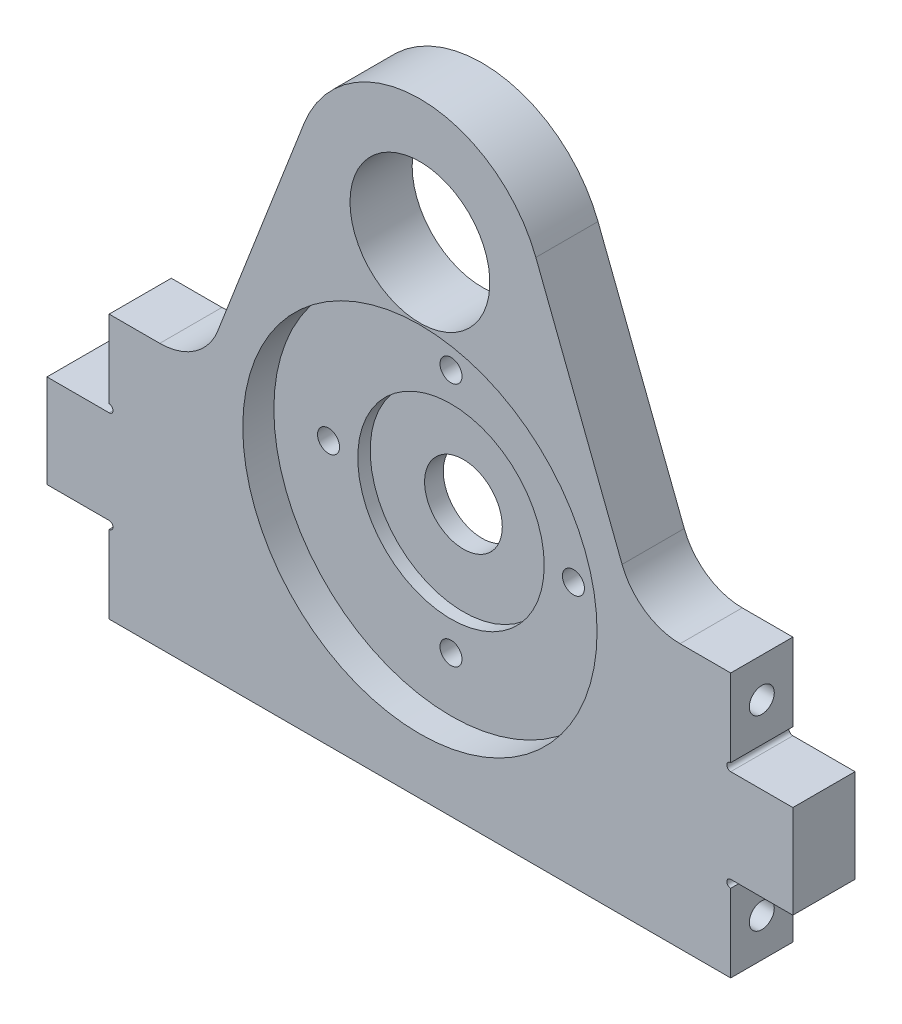
from build123d import *

# Parameters (mm, degrees)
SKETCH1_W                                      = 127
SKETCH1_H                                      = 152.4
BOSS_EXTRUDE1_DEPTH                            = 12.7
SKETCH2_R                                      = 14.2875
CUT_EXTRUDE1_DEPTH                             = 166.587741092
SKETCH3_R                                      = 7.9375
SKETCH3_R_2                                    = 1.016
CUT_EXTRUDE2_DEPTH                             = 137.930502446
SKETCH4_R                                      = 36.195
CUT_EXTRUDE3_DEPTH                             = 6.35
SKETCH5_R                                      = 19.05
CUT_EXTRUDE4_DEPTH                             = 2.54
CSK_FOR_8_FLAT_HEAD_MACHINE_SCREW1_D           = 4.4958
CSK_FOR_8_FLAT_HEAD_MACHINE_SCREW1_CSINK_D     = 8.4328
CSK_FOR_8_FLAT_HEAD_MACHINE_SCREW1_CSINK_ANGLE = 82
FILLET1_R                                      = 12.7
SKETCH8_W                                      = 127
SKETCH8_H                                      = 3.175
BOSS_EXTRUDE2_DEPTH                            = 12.7
F_1_4_20_TAPPED_HOLE1_AT_2_COUNT               = 2
F_1_4_20_TAPPED_HOLE1_AT_2_PITCH               = 38.1
SKETCH11_W                                     = 12.7
SKETCH11_H                                     = 19.05
BOSS_EXTRUDE3_DEPTH                            = 12.7
SKETCH12_R                                     = 0.79375
CUT_EXTRUDE5_DEPTH                             = 144.262529993


with BuildPart() as part:
    # Sketch1 → Boss-Extrude1 (new body)
    with BuildSketch(Plane.XY):
        with Locations((0, 76.2)):
            Rectangle(SKETCH1_W, SKETCH1_H)
    extrude(amount=BOSS_EXTRUDE1_DEPTH)

    # Sketch2 → Cut-Extrude1 (cut, through all)
    with BuildSketch(Plane(origin=(0, 0, 0), x_dir=(-1, 0, 0), z_dir=(0, 0, -1))):
        with BuildLine():
            Line((44.45, 50.8), (63.5, 50.8))
            Line((63.5, 50.8), (63.5, 152.4))
            Line((63.5, 152.4), (-63.5, 152.4))
            Line((-63.5, 152.4), (-63.5, 50.8))
            Line((-63.5, 50.8), (-44.45, 50.8))
            Line((-44.45, 50.8), (-23.686198751, 104.421913036))
            ThreePointArc((-23.686198751, 104.421913036), (0, 120.65), (23.686198751, 104.421913036))
            Line((23.686198751, 104.421913036), (44.45, 50.8))
        make_face()
        with Locations((0, 95.25)):
            Circle(SKETCH2_R)
    extrude(amount=-CUT_EXTRUDE1_DEPTH, mode=Mode.SUBTRACT)

    # Sketch3 → Cut-Extrude2 (cut, through all)
    with BuildSketch(Plane.XY.offset(12.7)):
        with Locations((0, 44.45)):
            Circle(SKETCH3_R)
        with Locations((-25.019, 44.45)):
            Circle(SKETCH3_R_2)
        with Locations((25.019, 44.45)):
            Circle(SKETCH3_R_2)
        with Locations((0, 69.469)):
            Circle(SKETCH3_R_2)
        with Locations((0, 19.431)):
            Circle(SKETCH3_R_2)
    extrude(amount=-CUT_EXTRUDE2_DEPTH, mode=Mode.SUBTRACT)

    # Sketch4 → Cut-Extrude3 (cut)
    with BuildSketch(Plane.XY.offset(12.7)):
        with Locations((0, 44.45)):
            Circle(SKETCH4_R)
    extrude(amount=-CUT_EXTRUDE3_DEPTH, mode=Mode.SUBTRACT)

    # Sketch5 → Cut-Extrude4 (cut)
    with BuildSketch(Plane.XY.offset(6.35)):
        with Locations((0, 44.45)):
            Circle(SKETCH5_R)
    extrude(amount=-CUT_EXTRUDE4_DEPTH, mode=Mode.SUBTRACT)

    # CSK for _8 Flat Head Machine Screw1 (through all)
    with Locations(Plane(origin=(0, 0, 0), x_dir=(-1, 0, 0), z_dir=(0, 0, -1))):
        with Locations((0, 69.469), (25.019, 44.45), (0, 19.431), (-25.019, 44.45)):
            CounterSinkHole(CSK_FOR_8_FLAT_HEAD_MACHINE_SCREW1_D / 2, CSK_FOR_8_FLAT_HEAD_MACHINE_SCREW1_CSINK_D / 2, counter_sink_angle=CSK_FOR_8_FLAT_HEAD_MACHINE_SCREW1_CSINK_ANGLE)

    # Fillet1
    fillet1_edges = [part.edges().sort_by_distance(p)[0] for p in [
        (-44.45, 50.8, 6.35),
        (44.45, 50.8, 6.35),
    ]]
    fillet(fillet1_edges, radius=FILLET1_R)

    # Sketch8 → Boss-Extrude2 (add)
    with BuildSketch(Plane(origin=(0, 0, 0), x_dir=(-1, 0, 0), z_dir=(0, 0, -1))):
        with Locations((0, -1.5875)):
            Rectangle(SKETCH8_W, SKETCH8_H)
    extrude(amount=-BOSS_EXTRUDE2_DEPTH)

    # Sketch9 → 1_4-20 Tapped Hole1 (revolve, cut)
    with BuildSketch(Plane(origin=(63.5, 42.8625, 6.35), x_dir=(0, 0, -1), z_dir=(0, 1, 0))):
        Polygon((0, 0), (0, 18.043816902), (2.5527, 16.51), (2.5527, 0), align=None)
    f_1_4_20_tapped_hole1 = revolve(axis=Axis((69.85, 42.8625, 6.35), (-1, 0, 0)), mode=Mode.SUBTRACT)

    # 1_4-20 Tapped Hole1 at 2: 1_4-20 Tapped Hole1 ×2
    with Locations(*[(0, -i * F_1_4_20_TAPPED_HOLE1_AT_2_PITCH, 0) for i in range(1, F_1_4_20_TAPPED_HOLE1_AT_2_COUNT)]):
        add(f_1_4_20_tapped_hole1, mode=Mode.SUBTRACT)

    # Sketch11 → Boss-Extrude3 (add)
    with BuildSketch(Plane(origin=(63.5, 0, 0), x_dir=(0, 0, -1), z_dir=(1, 0, 0))):
        with Locations((-6.35, 23.8125)):
            Rectangle(SKETCH11_W, SKETCH11_H)
    boss_extrude3 = extrude(amount=BOSS_EXTRUDE3_DEPTH)

    # Sketch12 → Cut-Extrude5 (cut, through all)
    with BuildSketch(Plane.XY.offset(12.7)):
        with Locations((63.5, 34.13125)):
            Circle(SKETCH12_R)
        with Locations((63.5, 13.49375)):
            Circle(SKETCH12_R)
    cut_extrude5 = extrude(amount=-CUT_EXTRUDE5_DEPTH, mode=Mode.SUBTRACT)

    # Mirror1: 1_4-20 Tapped Hole1, Boss-Extrude3, Cut-Extrude5 across plane
    add(f_1_4_20_tapped_hole1.mirror(Plane(origin=(0, 0, 0), x_dir=(0, 0, 1), z_dir=(1, 0, 0))), mode=Mode.SUBTRACT)
    add(boss_extrude3.mirror(Plane(origin=(0, 0, 0), x_dir=(0, 0, 1), z_dir=(1, 0, 0))))
    add(cut_extrude5.mirror(Plane(origin=(0, 0, 0), x_dir=(0, 0, 1), z_dir=(1, 0, 0))), mode=Mode.SUBTRACT)

    # Mirror1 copy 1 sketch → Mirror1 copy 1 (revolve, cut)
    with BuildSketch(Plane(origin=(-63.5, 4.7625, 6.35), x_dir=(0, 0, -1), z_dir=(0, 1, 0))):
        Polygon((0, 0), (0, -18.043816902), (2.5527, -16.51), (2.5527, 0), align=None)
    revolve(axis=Axis((-69.85, 4.7625, 6.35), (-1, 0, 0)), mode=Mode.SUBTRACT)


solid = part.part
